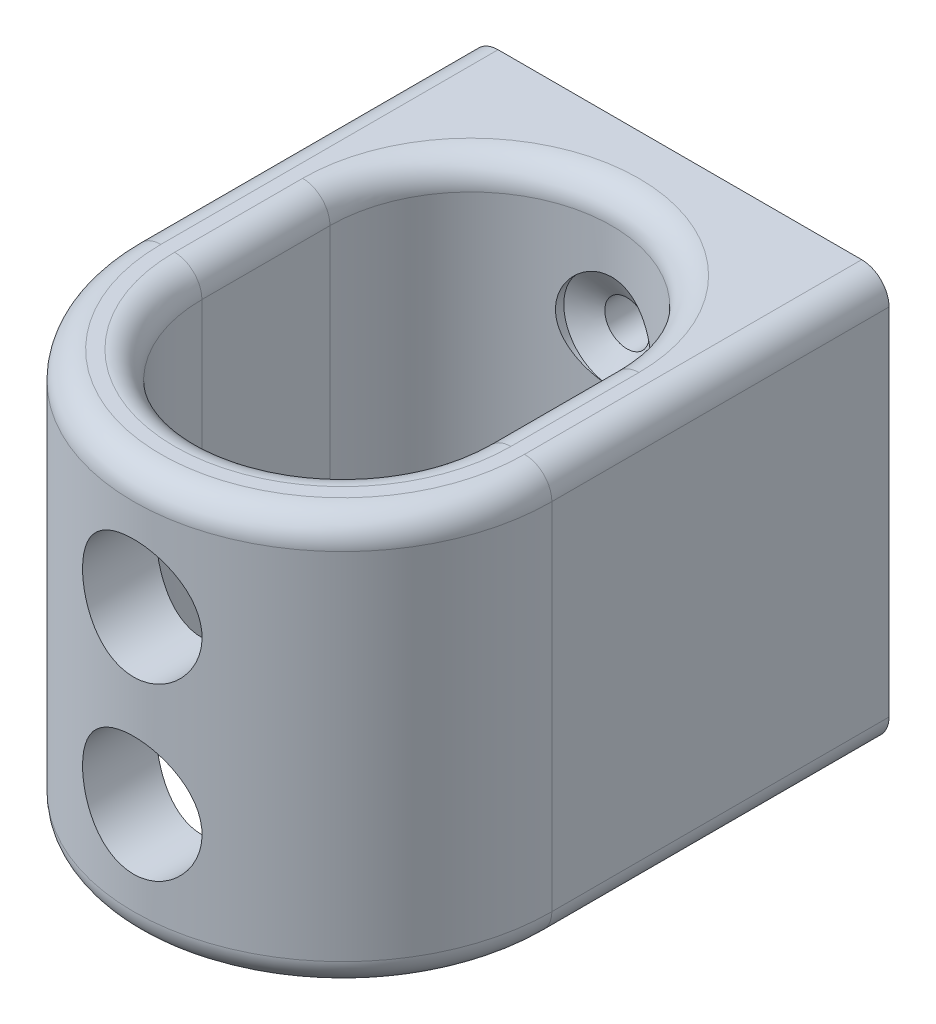
from build123d import *

# Parameters (mm, degrees)
BOSS_EXTRUDE1_DEPTH = 19.05
FILLET1_R           = 2.54


with BuildPart() as part:
    # Sketch1 → Boss-Extrude1 (new, symmetric)
    with BuildSketch(Plane(origin=(0, 0, 0), x_dir=(1, 0, 0), z_dir=(0, 1, 0))):
        with BuildLine():
            ThreePointArc((-19.446875, 0), (0, -19.446875), (19.446875, 0))
            Line((19.446875, 0), (19.446875, 31.353125))
            Line((19.446875, 31.353125), (-19.446875, 31.353125))
            Line((-19.446875, 31.353125), (-19.446875, 0))
        make_face()
        with BuildLine():
            ThreePointArc((13.096875, 0), (0, -13.096875), (-13.096875, 0))
            Line((-13.096875, 0), (-13.096875, 11.90625))
            ThreePointArc((-13.096875, 11.90625), (0, 25.003125), (13.096875, 11.90625))
            Line((13.096875, 11.90625), (13.096875, 0))
        make_face(mode=Mode.SUBTRACT)
    extrude(amount=BOSS_EXTRUDE1_DEPTH, both=True)

    # Sketch2 → Cut-Revolve1 (revolve, cut)
    with BuildSketch(Plane(origin=(0, 7.9375, 0), x_dir=(1, 0, 0), z_dir=(0, 1, 0))):
        Polygon((-2.06375, 31.353125), (-2.06375, 26.433924349), (-4.445, 25.003125), (-4.445, 0), (-5.55625, 0), (-5.55625, -19.446875), (-4.445, -19.446875), (0, -19.446875), (0, 31.353125), align=None)
    cut_revolve1 = revolve(axis=Axis((0, 7.9375, -28.179060189), (0, 0, 1)), mode=Mode.SUBTRACT)

    # Mirror1: Cut-Revolve1 across plane
    add(cut_revolve1.mirror(Plane.ZX), mode=Mode.SUBTRACT)

    # Fillet1
    fillet1_edges = [part.edges().sort_by_distance(p)[0] for p in [
        (19.446875, -19.05, -15.6765625),
        (0, -19.05, 19.446875),
        (13.096875, -19.05, -5.953125),
        (0, -19.05, 13.096875),
        (-13.096875, -19.05, -5.953125),
        (13.096875, 19.05, -5.953125),
        (0, 19.05, 13.096875),
        (-13.096875, 19.05, -5.953125),
        (19.446875, 19.05, -15.6765625),
        (0, 19.05, 19.446875),
        (-19.446875, -19.05, -15.6765625),
        (0, -19.05, -25.003125),
        (0, 19.05, -25.003125),
        (-19.446875, 19.05, -15.6765625),
    ]]
    fillet(fillet1_edges, radius=FILLET1_R)


solid = part.part
